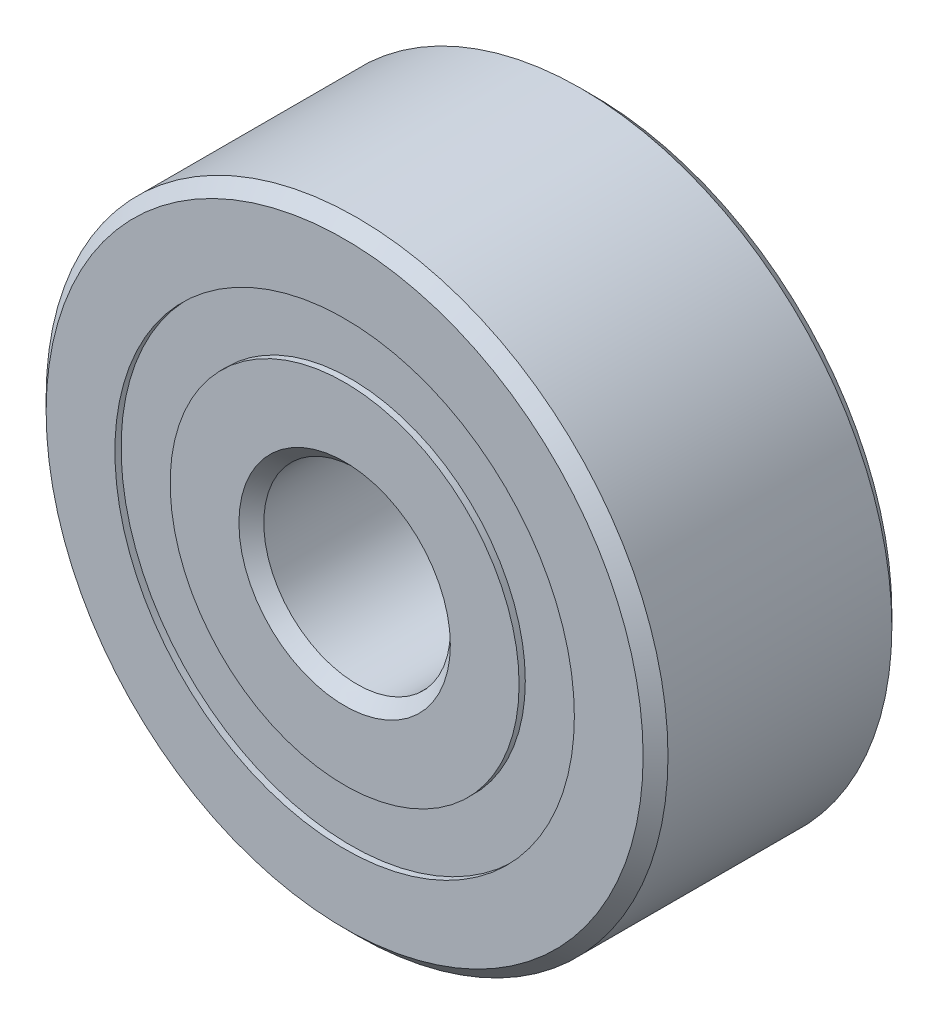
from build123d import *

# Parameters (mm, degrees)
CIRPATTERN1_COUNT = 9
SKETCH5_W         = 0.90619201
SKETCH5_H         = 0.888888888


with BuildPart() as part:
    # Sketch1 → Revolve1 (revolve)
    with BuildSketch(Plane(origin=(0, 0, 0), x_dir=(0, 0, -1), z_dir=(1, 0, 0))):
        with BuildLine():
            Line((1.8, 5), (-1.8, 5))
            Line((-1.8, 5), (-2, 4.8))
            Line((-2, 4.8), (-2, 3.694444444))
            Line((-2, 3.694444444), (-0.888888889, 3.694444444))
            ThreePointArc((-0.888888889, 3.694444444), (0, 4.24380799), (0.888888889, 3.694444444))
            Line((0.888888889, 3.694444444), (2, 3.694444444))
            Line((2, 3.694444444), (2, 4.8))
            Line((2, 4.8), (1.8, 5))
        make_face()
    revolve(axis=Axis((0, 0, 2), (0, 0, -1)))


with BuildPart() as body_2:
    # Sketch2 → Revolve2 (revolve)
    with BuildSketch(Plane(origin=(0, 0, 0), x_dir=(0, 0, -1), z_dir=(1, 0, 0))):
        with BuildLine():
            Line((-2, 2.805555556), (-0.888888889, 2.805555556))
            ThreePointArc((-0.888888889, 2.805555556), (0, 2.25619201), (0.888888889, 2.805555556))
            Line((0.888888889, 2.805555556), (2, 2.805555556))
            Line((2, 2.805555556), (2, 1.7))
            Line((2, 1.7), (1.8, 1.5))
            Line((1.8, 1.5), (-1.8, 1.5))
            Line((-1.8, 1.5), (-2, 1.7))
            Line((-2, 1.7), (-2, 2.805555556))
        make_face()
    revolve(axis=Axis((0, 0, 2), (0, 0, -1)))


with BuildPart() as body_3:
    # Sketch3 → Revolve3 (revolve)
    with BuildSketch(Plane(origin=(0, 0, 0), x_dir=(0, 0, -1), z_dir=(1, 0, 0))):
        with BuildLine():
            Line((-0.99380799, 3.25), (0.99380799, 3.25))
            ThreePointArc((0.99380799, 3.25), (0, 4.24380799), (-0.99380799, 3.25))
        make_face()
    revolve(axis=Axis((0, 3.25, 0.99380799), (0, 0, -1)))


with BuildPart() as cirpattern1_1:
    # CirPattern1: pattern copy
    add(body_3.part.rotate(Axis((0, 0, -2), (0, 0, 1)), 1 * 360 / CIRPATTERN1_COUNT))


with BuildPart() as cirpattern1_2:
    # CirPattern1: pattern copy
    add(body_3.part.rotate(Axis((0, 0, -2), (0, 0, 1)), 2 * 360 / CIRPATTERN1_COUNT))


with BuildPart() as cirpattern1_3:
    # CirPattern1: pattern copy
    add(body_3.part.rotate(Axis((0, 0, -2), (0, 0, 1)), 3 * 360 / CIRPATTERN1_COUNT))


with BuildPart() as cirpattern1_4:
    # CirPattern1: pattern copy
    add(body_3.part.rotate(Axis((0, 0, -2), (0, 0, 1)), 4 * 360 / CIRPATTERN1_COUNT))


with BuildPart() as cirpattern1_5:
    # CirPattern1: pattern copy
    add(body_3.part.rotate(Axis((0, 0, -2), (0, 0, 1)), 5 * 360 / CIRPATTERN1_COUNT))


with BuildPart() as cirpattern1_6:
    # CirPattern1: pattern copy
    add(body_3.part.rotate(Axis((0, 0, -2), (0, 0, 1)), 6 * 360 / CIRPATTERN1_COUNT))


with BuildPart() as cirpattern1_7:
    # CirPattern1: pattern copy
    add(body_3.part.rotate(Axis((0, 0, -2), (0, 0, 1)), 7 * 360 / CIRPATTERN1_COUNT))


with BuildPart() as cirpattern1_8:
    # CirPattern1: pattern copy
    add(body_3.part.rotate(Axis((0, 0, -2), (0, 0, 1)), 8 * 360 / CIRPATTERN1_COUNT))


with BuildPart() as body_12:
    # Sketch5 → Revolve5 (revolve)
    with BuildSketch(Plane(origin=(0, 0, 0), x_dir=(0, 0, -1), z_dir=(1, 0, 0))):
        with Locations((-1.446903995, 3.25)):
            Rectangle(SKETCH5_W, SKETCH5_H)
        with Locations((1.446903995, 3.25)):
            Rectangle(SKETCH5_W, SKETCH5_H)
    revolve(axis=Axis((0, 0, 2), (0, 0, -1)))


solid = Compound([part.part, body_2.part, body_3.part, cirpattern1_1.part, cirpattern1_2.part, cirpattern1_3.part, cirpattern1_4.part, cirpattern1_5.part, cirpattern1_6.part, cirpattern1_7.part, cirpattern1_8.part, body_12.part])
